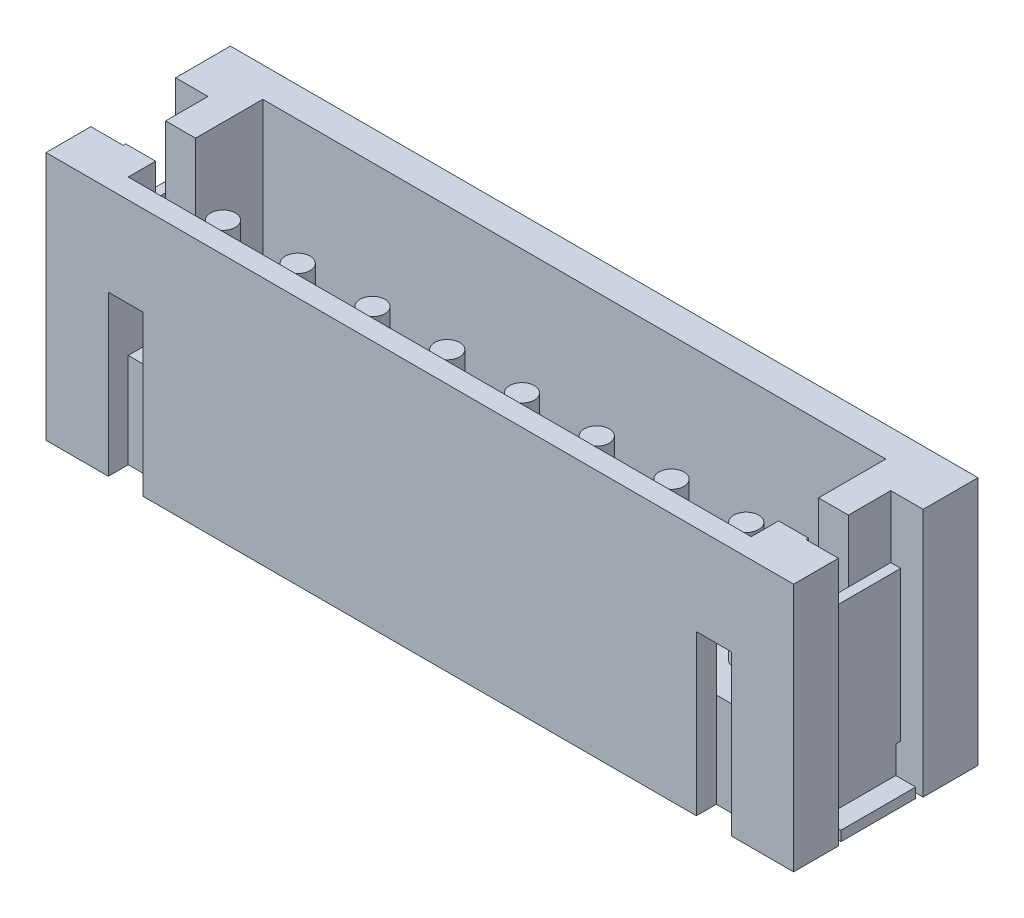
from build123d import *

# Parameters (mm, degrees)
SKETCH1_W           = 1.25
SKETCH1_H           = 5
BOSS_EXTRUDE1_DEPTH = 3.1
BOSS_EXTRUDE2_DEPTH = 12.5
BOSS_EXTRUDE3_DEPTH = 1.250000167
CUT_EXTRUDE1_DEPTH  = 0.7
CUT_EXTRUDE2_DEPTH  = 0.7
BOSS_EXTRUDE4_DEPTH = 0.6
SKETCH7_W           = 0.45
SKETCH7_H           = 1.7
CUT_EXTRUDE3_DEPTH  = 6.0000001
CUT_EXTRUDE4_REACH  = 16.55
SKETCH8_W           = 0.8
SKETCH8_H           = 1.25
SKETCH9_W           = 0.85
SKETCH9_H           = 1.25
CUT_EXTRUDE5_DEPTH  = 0.2
SKETCH10_W          = 0.05
SKETCH10_H          = 1.25
CUT_EXTRUDE6_DEPTH  = 0.2
CUT_EXTRUDE7_REACH  = 3.8
SKETCH12_W          = 0.6
SKETCH12_H          = 0.8
SKETCH13_W          = 0.45
SKETCH13_H          = 1.7
CUT_EXTRUDE8_DEPTH  = 6.0000001
SKETCH14_W          = 0.8
SKETCH14_H          = 1.25
CUT_EXTRUDE9_DEPTH  = 15.5500001
SKETCH15_W          = 0.85
SKETCH15_H          = 1.25
CUT_EXTRUDE10_DEPTH = 0.2
CUT_EXTRUDE11_REACH = 2.65
SKETCH17_W          = 0.1
SKETCH17_H          = 0.75
SKETCH18_W          = 1.5
SKETCH18_H          = 0.2
BOSS_EXTRUDE5_DEPTH = 0.4
CUT_EXTRUDE12_REACH = 2.65
SKETCH20_W          = 0.1
SKETCH20_H          = 0.75
CUT_EXTRUDE13_REACH = 2.65
SKETCH22_W          = 0.75
SKETCH22_H          = 0.1
SKETCH23_W          = 1.5
SKETCH23_H          = 0.2
BOSS_EXTRUDE6_DEPTH = 0.4
CUT_EXTRUDE14_REACH = 2.65
SKETCH25_W          = 0.75
SKETCH25_H          = 0.1
SKETCH26_W          = 0.05
SKETCH26_H          = 1.25
CUT_EXTRUDE15_DEPTH = 0.2
CUT_EXTRUDE16_REACH = 3.8
SKETCH28_W          = 0.6
SKETCH28_H          = 0.8
SKETCH29_W          = 0.25
SKETCH29_H          = 2.4
SKETCH30_W          = 0.25
SKETCH30_H          = 2.4
SKETCH31_W          = 0.25
SKETCH31_H          = 2.4
SKETCH32_W          = 0.25
SKETCH32_H          = 2.4
SKETCH33_W          = 0.25
SKETCH33_H          = 2.4
SKETCH34_W          = 0.25
SKETCH34_H          = 2.4
SKETCH35_W          = 0.25
SKETCH35_H          = 2.4
SKETCH36_W          = 0.25
SKETCH36_H          = 2.4
SKETCH37_W          = 0.25
SKETCH37_H          = 1.5
SKETCH38_W          = 0.25
SKETCH38_H          = 1.5
SKETCH39_W          = 0.25
SKETCH39_H          = 1.5
SKETCH40_W          = 0.25
SKETCH40_H          = 1.5
SKETCH41_W          = 0.25
SKETCH41_H          = 1.5
SKETCH42_W          = 0.25
SKETCH42_H          = 1.5
SKETCH43_W          = 0.25
SKETCH43_H          = 1.5
SKETCH44_W          = 0.25
SKETCH44_H          = 1.5


with BuildPart() as part:
    # Sketch1 → Boss-Extrude1 (new body)
    with BuildSketch(Plane.XY):
        with Locations((-6.875, 2.5)):
            Rectangle(SKETCH1_W, SKETCH1_H)
    extrude(amount=-BOSS_EXTRUDE1_DEPTH)

    # Sketch2 → Boss-Extrude2 (add)
    with BuildSketch(Plane(origin=(-6.25, 0, 0), x_dir=(0, 0, -1), z_dir=(1, 0, 0))):
        with BuildLine():
            Line((0, 5), (0.4, 5))
            Line((0.4, 5), (0.4, 1.9))
            Line((0.4, 1.9), (1.75, 1.9))
            Line((1.75, 1.9), (2.05, 1.6))
            Line((2.05, 1.6), (3.1, 1.6))
            add(Edge.make_bspline(
                [(3.1, 0), (3.1, 1.6)],
                knots=[0, 0, 0.32, 0.32], degree=1))
            Line((3.1, 0), (0, 0))
            Line((0, 0), (0, 5))
        make_face()
    extrude(amount=BOSS_EXTRUDE2_DEPTH)

    # Sketch3 → Boss-Extrude3 (add)
    with BuildSketch(Plane(origin=(6.25, 0, 0), x_dir=(0, 0, -1), z_dir=(1, 0, 0))):
        with BuildLine():
            Line((3.1, 0), (0, 0))
            Line((0, 0), (0, 5))
            Line((0, 5), (3.1, 5))
            add(Edge.make_bspline(
                [(3.1, 0), (3.1, 5)],
                knots=[0, 0, 1, 1], degree=1))
        make_face()
    extrude(amount=BOSS_EXTRUDE3_DEPTH)

    # Sketch4 → Cut-Extrude1 (cut)
    with BuildSketch(Plane(origin=(6.25, 0, 0), x_dir=(0, 0, -1), z_dir=(1, 0, 0))):
        Polygon((0.4, 1.9), (0.4, 3.2), (0, 3.2), (0, 0), (0.4, 0), align=None)
    extrude(amount=-CUT_EXTRUDE1_DEPTH, mode=Mode.SUBTRACT)

    # Sketch5 → Cut-Extrude2 (cut)
    with BuildSketch(Plane(origin=(-6.25, 0, 0), x_dir=(0, -1, 0), z_dir=(-1, 0, 0))):
        Polygon((-1.9, -0.4), (0, -0.4), (0, 0), (-3.2, 0), (-3.2, -0.4), align=None)
    extrude(amount=-CUT_EXTRUDE2_DEPTH, mode=Mode.SUBTRACT)

    # Sketch6 → Boss-Extrude4 (add)
    with BuildSketch(Plane(origin=(0, 0, -3.1), x_dir=(-1, 0, 0), z_dir=(0, 0, -1))):
        with BuildLine():
            add(Edge.make_bspline(
                [(7.5, 0), (-7.5, 0)],
                knots=[0, 0, 1, 1], degree=1))
            add(Edge.make_bspline(
                [(-7.5, 0), (-7.5, 5)],
                knots=[0, 0, 1, 1], degree=1))
            add(Edge.make_bspline(
                [(7.5, 5), (-7.5, 5)],
                knots=[0, 0, 1, 1], degree=1))
            add(Edge.make_bspline(
                [(7.5, 0), (7.5, 5)],
                knots=[0, 0, 1, 1], degree=1))
        make_face()
    extrude(amount=BOSS_EXTRUDE4_DEPTH)

    # Sketch7 → Cut-Extrude3 (cut, through all)
    with BuildSketch(Plane.XZ):
        with Locations((-7.275, -1.75)):
            Rectangle(SKETCH7_W, SKETCH7_H)
    extrude(amount=-CUT_EXTRUDE3_DEPTH, mode=Mode.SUBTRACT)

    # Sketch8 → Cut-Extrude4 (cut, up to next)
    with BuildSketch(Plane.ZY.offset(7.05), mode=Mode.PRIVATE) as cut_extrude4_sk1:
        with Locations((-1.35, 4.375)):
            Rectangle(SKETCH8_W, SKETCH8_H)
    cut_extrude4_tool1 = extrude(cut_extrude4_sk1.sketch, amount=-CUT_EXTRUDE4_REACH, mode=Mode.PRIVATE) & part.part
    add(cut_extrude4_tool1.solids().sort_by_distance((-7.05, 4.375, -1.35))[0], mode=Mode.SUBTRACT)

    # Sketch9 → Cut-Extrude5 (cut)
    with BuildSketch(Plane.ZY.offset(7.05)):
        with Locations((-2.175, 4.375)):
            Rectangle(SKETCH9_W, SKETCH9_H)
    extrude(amount=-CUT_EXTRUDE5_DEPTH, mode=Mode.SUBTRACT)

    # Sketch10 → Cut-Extrude6 (cut)
    with BuildSketch(Plane.ZY.offset(7.05)):
        with Locations((-0.925, 4.375)):
            Rectangle(SKETCH10_W, SKETCH10_H)
    extrude(amount=-CUT_EXTRUDE6_DEPTH, mode=Mode.SUBTRACT)

    # Sketch12 → Cut-Extrude7 (cut, up to next)
    with BuildSketch(Plane.XZ.offset(-3.2), mode=Mode.PRIVATE) as cut_extrude7_sk1:
        with Locations((-6.55, -1.35)):
            Rectangle(SKETCH12_W, SKETCH12_H)
    cut_extrude7_tool1 = extrude(cut_extrude7_sk1.sketch, amount=-CUT_EXTRUDE7_REACH, mode=Mode.PRIVATE) & part.part
    add(cut_extrude7_tool1.solids().sort_by_distance((-6.55, 3.2, -1.35))[0], mode=Mode.SUBTRACT)

    # Sketch13 → Cut-Extrude8 (cut, through all)
    with BuildSketch(Plane.XZ):
        with Locations((7.275, -1.75)):
            Rectangle(SKETCH13_W, SKETCH13_H)
    extrude(amount=-CUT_EXTRUDE8_DEPTH, mode=Mode.SUBTRACT)

    # Sketch14 → Cut-Extrude9 (cut, through all)
    with BuildSketch(Plane(origin=(7.05, 0, 0), x_dir=(0, 0, -1), z_dir=(1, 0, 0))):
        with Locations((1.35, 4.375)):
            Rectangle(SKETCH14_W, SKETCH14_H)
    extrude(amount=-CUT_EXTRUDE9_DEPTH, mode=Mode.SUBTRACT)

    # Sketch15 → Cut-Extrude10 (cut)
    with BuildSketch(Plane(origin=(7.05, 0, 0), x_dir=(0, 0, -1), z_dir=(1, 0, 0))):
        with Locations((2.175, 4.375)):
            Rectangle(SKETCH15_W, SKETCH15_H)
    extrude(amount=-CUT_EXTRUDE10_DEPTH, mode=Mode.SUBTRACT)

    # Sketch17 → Cut-Extrude11 (cut, up to next)
    with BuildSketch(Plane(origin=(-6.85, 0, 0), x_dir=(0, 0, -1), z_dir=(1, 0, 0)), mode=Mode.PRIVATE) as cut_extrude11_sk1:
        with Locations((0.95, 0.375)):
            Rectangle(SKETCH17_W, SKETCH17_H)
    cut_extrude11_tool1 = extrude(cut_extrude11_sk1.sketch, amount=-CUT_EXTRUDE11_REACH, mode=Mode.PRIVATE) & part.part
    add(cut_extrude11_tool1.solids().sort_by_distance((-6.85, 0.375, -0.95))[0], mode=Mode.SUBTRACT)

    # Sketch18 → Boss-Extrude5 (add)
    with BuildSketch(Plane.ZY.offset(7.05)):
        with Locations((-1.75, 0.1)):
            Rectangle(SKETCH18_W, SKETCH18_H)
    extrude(amount=BOSS_EXTRUDE5_DEPTH)

    # Sketch20 → Cut-Extrude12 (cut, up to next)
    with BuildSketch(Plane(origin=(-6.85, 0, 0), x_dir=(0, 0, -1), z_dir=(1, 0, 0)), mode=Mode.PRIVATE) as cut_extrude12_sk1:
        with Locations((2.55, 0.375)):
            Rectangle(SKETCH20_W, SKETCH20_H)
    cut_extrude12_tool1 = extrude(cut_extrude12_sk1.sketch, amount=-CUT_EXTRUDE12_REACH, mode=Mode.PRIVATE) & part.part
    add(cut_extrude12_tool1.solids().sort_by_distance((-6.85, 0.375, -2.55))[0], mode=Mode.SUBTRACT)

    # Sketch22 → Cut-Extrude13 (cut, up to next)
    with BuildSketch(Plane(origin=(6.85, 0, 0), x_dir=(0, -1, 0), z_dir=(-1, 0, 0)), mode=Mode.PRIVATE) as cut_extrude13_sk1:
        with Locations((-0.375, -2.55)):
            Rectangle(SKETCH22_W, SKETCH22_H)
    cut_extrude13_tool1 = extrude(cut_extrude13_sk1.sketch, amount=-CUT_EXTRUDE13_REACH, mode=Mode.PRIVATE) & part.part
    add(cut_extrude13_tool1.solids().sort_by_distance((6.85, 0.375, -2.55))[0], mode=Mode.SUBTRACT)

    # Sketch23 → Boss-Extrude6 (add)
    with BuildSketch(Plane(origin=(7.05, 0, 0), x_dir=(0, 0, -1), z_dir=(1, 0, 0))):
        with Locations((1.75, 0.1)):
            Rectangle(SKETCH23_W, SKETCH23_H)
    extrude(amount=BOSS_EXTRUDE6_DEPTH)

    # Sketch25 → Cut-Extrude14 (cut, up to next)
    with BuildSketch(Plane(origin=(6.85, 0, 0), x_dir=(0, -1, 0), z_dir=(-1, 0, 0)), mode=Mode.PRIVATE) as cut_extrude14_sk1:
        with Locations((-0.375, -0.95)):
            Rectangle(SKETCH25_W, SKETCH25_H)
    cut_extrude14_tool1 = extrude(cut_extrude14_sk1.sketch, amount=-CUT_EXTRUDE14_REACH, mode=Mode.PRIVATE) & part.part
    add(cut_extrude14_tool1.solids().sort_by_distance((6.85, 0.375, -0.95))[0], mode=Mode.SUBTRACT)

    # Sketch26 → Cut-Extrude15 (cut)
    with BuildSketch(Plane(origin=(7.05, 0, 0), x_dir=(0, 0, -1), z_dir=(1, 0, 0))):
        with Locations((0.925, 4.375)):
            Rectangle(SKETCH26_W, SKETCH26_H)
    extrude(amount=-CUT_EXTRUDE15_DEPTH, mode=Mode.SUBTRACT)

    # Sketch28 → Cut-Extrude16 (cut, up to next)
    with BuildSketch(Plane.XZ.offset(-3.2), mode=Mode.PRIVATE) as cut_extrude16_sk1:
        with Locations((6.55, -1.35)):
            Rectangle(SKETCH28_W, SKETCH28_H)
    cut_extrude16_tool1 = extrude(cut_extrude16_sk1.sketch, amount=-CUT_EXTRUDE16_REACH, mode=Mode.PRIVATE) & part.part
    add(cut_extrude16_tool1.solids().sort_by_distance((6.55, 3.2, -1.35))[0], mode=Mode.SUBTRACT)

    # Sketch29 → Revolve1 (revolve)
    with BuildSketch(Plane(origin=(0, 0, -1.3), x_dir=(-1, 0, 0), z_dir=(0, 0, -1))):
        with Locations((-5.375, 3.1)):
            Rectangle(SKETCH29_W, SKETCH29_H)
    revolve(axis=Axis((5.25, 1.9, -1.3), (0, 1, 0)))

    # Sketch30 → Revolve2 (revolve)
    with BuildSketch(Plane(origin=(0, 0, -1.3), x_dir=(-1, 0, 0), z_dir=(0, 0, -1))):
        with Locations((-3.875, 3.1)):
            Rectangle(SKETCH30_W, SKETCH30_H)
    revolve(axis=Axis((3.75, 1.9, -1.3), (0, 1, 0)))

    # Sketch31 → Revolve3 (revolve)
    with BuildSketch(Plane(origin=(0, 0, -1.3), x_dir=(-1, 0, 0), z_dir=(0, 0, -1))):
        with Locations((-2.375, 3.1)):
            Rectangle(SKETCH31_W, SKETCH31_H)
    revolve(axis=Axis((2.25, 1.9, -1.3), (0, 1, 0)))

    # Sketch32 → Revolve4 (revolve)
    with BuildSketch(Plane(origin=(0, 0, -1.3), x_dir=(-1, 0, 0), z_dir=(0, 0, -1))):
        with Locations((-0.875, 3.1)):
            Rectangle(SKETCH32_W, SKETCH32_H)
    revolve(axis=Axis((0.75, 1.9, -1.3), (0, 1, 0)))

    # Sketch33 → Revolve5 (revolve)
    with BuildSketch(Plane(origin=(0, 0, -1.3), x_dir=(-1, 0, 0), z_dir=(0, 0, -1))):
        with Locations((0.625, 3.1)):
            Rectangle(SKETCH33_W, SKETCH33_H)
    revolve(axis=Axis((-0.75, 1.9, -1.3), (0, 1, 0)))

    # Sketch34 → Revolve6 (revolve)
    with BuildSketch(Plane(origin=(0, 0, -1.3), x_dir=(-1, 0, 0), z_dir=(0, 0, -1))):
        with Locations((2.125, 3.1)):
            Rectangle(SKETCH34_W, SKETCH34_H)
    revolve(axis=Axis((-2.25, 1.9, -1.3), (0, 1, 0)))

    # Sketch35 → Revolve7 (revolve)
    with BuildSketch(Plane(origin=(0, 0, -1.3), x_dir=(-1, 0, 0), z_dir=(0, 0, -1))):
        with Locations((3.625, 3.1)):
            Rectangle(SKETCH35_W, SKETCH35_H)
    revolve(axis=Axis((-3.75, 1.9, -1.3), (0, 1, 0)))

    # Sketch36 → Revolve8 (revolve)
    with BuildSketch(Plane(origin=(0, 0, -1.3), x_dir=(-1, 0, 0), z_dir=(0, 0, -1))):
        with Locations((5.125, 3.1)):
            Rectangle(SKETCH36_W, SKETCH36_H)
    revolve(axis=Axis((-5.25, 1.9, -1.3), (0, 1, 0)))

    # Sketch37 → Revolve9 (revolve)
    with BuildSketch(Plane.XZ.offset(-0.25)):
        with Locations((5.375, -4.45)):
            Rectangle(SKETCH37_W, SKETCH37_H)
    revolve(axis=Axis((5.25, 0.25, -3.7), (0, 0, -1)))

    # Sketch38 → Revolve10 (revolve)
    with BuildSketch(Plane.XZ.offset(-0.25)):
        with Locations((3.875, -4.45)):
            Rectangle(SKETCH38_W, SKETCH38_H)
    revolve(axis=Axis((3.75, 0.25, -3.7), (0, 0, -1)))

    # Sketch39 → Revolve11 (revolve)
    with BuildSketch(Plane.XZ.offset(-0.25)):
        with Locations((2.375, -4.45)):
            Rectangle(SKETCH39_W, SKETCH39_H)
    revolve(axis=Axis((2.25, 0.25, -3.7), (0, 0, -1)))

    # Sketch40 → Revolve12 (revolve)
    with BuildSketch(Plane.XZ.offset(-0.25)):
        with Locations((0.875, -4.45)):
            Rectangle(SKETCH40_W, SKETCH40_H)
    revolve(axis=Axis((0.75, 0.25, -3.7), (0, 0, -1)))

    # Sketch41 → Revolve13 (revolve)
    with BuildSketch(Plane.XZ.offset(-0.25)):
        with Locations((-0.625, -4.45)):
            Rectangle(SKETCH41_W, SKETCH41_H)
    revolve(axis=Axis((-0.75, 0.25, -3.7), (0, 0, -1)))

    # Sketch42 → Revolve14 (revolve)
    with BuildSketch(Plane.XZ.offset(-0.25)):
        with Locations((-2.125, -4.45)):
            Rectangle(SKETCH42_W, SKETCH42_H)
    revolve(axis=Axis((-2.25, 0.25, -3.7), (0, 0, -1)))

    # Sketch43 → Revolve15 (revolve)
    with BuildSketch(Plane.XZ.offset(-0.25)):
        with Locations((-3.625, -4.45)):
            Rectangle(SKETCH43_W, SKETCH43_H)
    revolve(axis=Axis((-3.75, 0.25, -3.7), (0, 0, -1)))

    # Sketch44 → Revolve16 (revolve)
    with BuildSketch(Plane.XZ.offset(-0.25)):
        with Locations((-5.125, -4.45)):
            Rectangle(SKETCH44_W, SKETCH44_H)
    revolve(axis=Axis((-5.25, 0.25, -3.7), (0, 0, -1)))


solid = part.part
